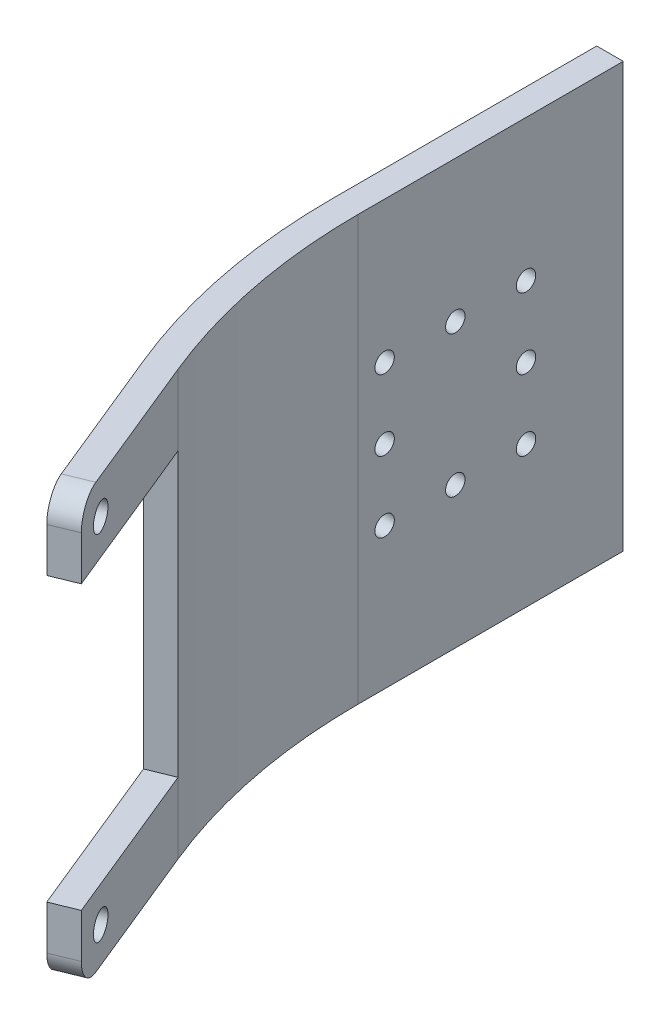
from build123d import *

# Parameters (mm, degrees)
EXTRUSION1_DEPTH = 48
EXTRUSION3_REACH = 32.949
ESQUISSE2_R      = 1.5
ESQUISSE2_W      = 20
ESQUISSE2_H      = 32
CONG_1_R         = 3
EXTRUSION4_REACH = 5
ESQUISSE3_R      = 1.1


with BuildPart() as part:
    # Esquisse1 → Extrusion1 (new body)
    with BuildSketch(Plane(origin=(0, 0, 0), x_dir=(1, 0, 0), z_dir=(0, 1, 0))):
        with BuildLine():
            Line((0, 0), (0, 30))
            Line((0, 30), (3, 30))
            Line((3, 30), (3, 0))
            ThreePointArc((3, 0), (4.257195182, -12.918344113), (7.981600437, -25.351885839))
            Line((7.981600437, -25.351885839), (15.549327553, -43.864840933))
            Line((15.549327553, -43.864840933), (12.772384289, -45))
            Line((12.772384289, -45), (5.204657173, -26.487044906))
            ThreePointArc((5.204657173, -26.487044906), (1.313487503, -13.496777432), (0, 0))
        make_face()
    extrude(amount=EXTRUSION1_DEPTH)

    # Esquisse2 → Extrusion3 (cut, up to next)
    with BuildSketch(Plane(origin=(-4.817679226, 0, 1.969371261), x_dir=(0.378386356, 0, 0.925647755), z_dir=(-0.925647755, 0, 0.378386356)), mode=Mode.PRIVATE) as extrusion3_sk1:
        with Locations((42.487044906, 4)):
            Circle(ESQUISSE2_R)
    extrusion3_tool1 = extrude(extrusion3_sk1.sketch, amount=-EXTRUSION3_REACH, mode=Mode.PRIVATE) & part.part
    add(extrusion3_tool1.solids().sort_by_distance((11.258839, 4, 41.297409))[0], mode=Mode.SUBTRACT)
    # Esquisse2 → Extrusion3 (cut, up to next)
    with BuildSketch(Plane(origin=(-4.817679226, 0, 1.969371261), x_dir=(0.378386356, 0, 0.925647755), z_dir=(-0.925647755, 0, 0.378386356)), mode=Mode.PRIVATE) as extrusion3_sk2:
        with Locations((42.487044906, 44)):
            Circle(ESQUISSE2_R)
    extrusion3_tool2 = extrude(extrusion3_sk2.sketch, amount=-EXTRUSION3_REACH, mode=Mode.PRIVATE) & part.part
    add(extrusion3_tool2.solids().sort_by_distance((11.258839, 44, 41.297409))[0], mode=Mode.SUBTRACT)
    # Esquisse2 → Extrusion3 (cut, up to next)
    with BuildSketch(Plane(origin=(-4.817679226, 0, 1.969371261), x_dir=(0.378386356, 0, 0.925647755), z_dir=(-0.925647755, 0, 0.378386356)), mode=Mode.PRIVATE) as extrusion3_sk3:
        with Locations((36.487044906, 24)):
            Rectangle(ESQUISSE2_W, ESQUISSE2_H)
    extrusion3_tool3 = extrude(extrusion3_sk3.sketch, amount=-EXTRUSION3_REACH, mode=Mode.PRIVATE) & part.part
    add(extrusion3_tool3.solids().sort_by_distance((8.988521, 24, 35.743522))[0], mode=Mode.SUBTRACT)

    # Congé1
    cong_1_edges = [part.edges().sort_by_distance(p)[0] for p in [
        (14.160855921, 48, 44.432420466),
        (14.160855921, 0, 44.432420466),
    ]]
    fillet(cong_1_edges, radius=CONG_1_R)

    # Esquisse3 → Extrusion4 (cut, up to next)
    with BuildSketch(Plane(origin=(3, 0, 0), x_dir=(0, 0, -1), z_dir=(1, 0, 0)), mode=Mode.PRIVATE) as extrusion4_sk1:
        with Locations((3, 16)):
            Circle(ESQUISSE3_R)
    extrusion4_tool1 = extrude(extrusion4_sk1.sketch, amount=-EXTRUSION4_REACH, mode=Mode.PRIVATE) & part.part
    add(extrusion4_tool1.solids().sort_by_distance((3, 16, -3))[0], mode=Mode.SUBTRACT)
    # Esquisse3 → Extrusion4 (cut, up to next)
    with BuildSketch(Plane(origin=(3, 0, 0), x_dir=(0, 0, -1), z_dir=(1, 0, 0)), mode=Mode.PRIVATE) as extrusion4_sk2:
        with Locations((11, 16)):
            Circle(ESQUISSE3_R)
    extrusion4_tool2 = extrude(extrusion4_sk2.sketch, amount=-EXTRUSION4_REACH, mode=Mode.PRIVATE) & part.part
    add(extrusion4_tool2.solids().sort_by_distance((3, 16, -11))[0], mode=Mode.SUBTRACT)
    # Esquisse3 → Extrusion4 (cut, up to next)
    with BuildSketch(Plane(origin=(3, 0, 0), x_dir=(0, 0, -1), z_dir=(1, 0, 0)), mode=Mode.PRIVATE) as extrusion4_sk3:
        with Locations((19, 16)):
            Circle(ESQUISSE3_R)
    extrusion4_tool3 = extrude(extrusion4_sk3.sketch, amount=-EXTRUSION4_REACH, mode=Mode.PRIVATE) & part.part
    add(extrusion4_tool3.solids().sort_by_distance((3, 16, -19))[0], mode=Mode.SUBTRACT)
    # Esquisse3 → Extrusion4 (cut, up to next)
    with BuildSketch(Plane(origin=(3, 0, 0), x_dir=(0, 0, -1), z_dir=(1, 0, 0)), mode=Mode.PRIVATE) as extrusion4_sk4:
        with Locations((3, 24)):
            Circle(ESQUISSE3_R)
    extrusion4_tool4 = extrude(extrusion4_sk4.sketch, amount=-EXTRUSION4_REACH, mode=Mode.PRIVATE) & part.part
    add(extrusion4_tool4.solids().sort_by_distance((3, 24, -3))[0], mode=Mode.SUBTRACT)
    # Esquisse3 → Extrusion4 (cut, up to next)
    with BuildSketch(Plane(origin=(3, 0, 0), x_dir=(0, 0, -1), z_dir=(1, 0, 0)), mode=Mode.PRIVATE) as extrusion4_sk5:
        with Locations((19, 24)):
            Circle(ESQUISSE3_R)
    extrusion4_tool5 = extrude(extrusion4_sk5.sketch, amount=-EXTRUSION4_REACH, mode=Mode.PRIVATE) & part.part
    add(extrusion4_tool5.solids().sort_by_distance((3, 24, -19))[0], mode=Mode.SUBTRACT)
    # Esquisse3 → Extrusion4 (cut, up to next)
    with BuildSketch(Plane(origin=(3, 0, 0), x_dir=(0, 0, -1), z_dir=(1, 0, 0)), mode=Mode.PRIVATE) as extrusion4_sk6:
        with Locations((19, 32)):
            Circle(ESQUISSE3_R)
    extrusion4_tool6 = extrude(extrusion4_sk6.sketch, amount=-EXTRUSION4_REACH, mode=Mode.PRIVATE) & part.part
    add(extrusion4_tool6.solids().sort_by_distance((3, 32, -19))[0], mode=Mode.SUBTRACT)
    # Esquisse3 → Extrusion4 (cut, up to next)
    with BuildSketch(Plane(origin=(3, 0, 0), x_dir=(0, 0, -1), z_dir=(1, 0, 0)), mode=Mode.PRIVATE) as extrusion4_sk7:
        with Locations((11, 32)):
            Circle(ESQUISSE3_R)
    extrusion4_tool7 = extrude(extrusion4_sk7.sketch, amount=-EXTRUSION4_REACH, mode=Mode.PRIVATE) & part.part
    add(extrusion4_tool7.solids().sort_by_distance((3, 32, -11))[0], mode=Mode.SUBTRACT)
    # Esquisse3 → Extrusion4 (cut, up to next)
    with BuildSketch(Plane(origin=(3, 0, 0), x_dir=(0, 0, -1), z_dir=(1, 0, 0)), mode=Mode.PRIVATE) as extrusion4_sk8:
        with Locations((3, 32)):
            Circle(ESQUISSE3_R)
    extrusion4_tool8 = extrude(extrusion4_sk8.sketch, amount=-EXTRUSION4_REACH, mode=Mode.PRIVATE) & part.part
    add(extrusion4_tool8.solids().sort_by_distance((3, 32, -3))[0], mode=Mode.SUBTRACT)


solid = part.part
